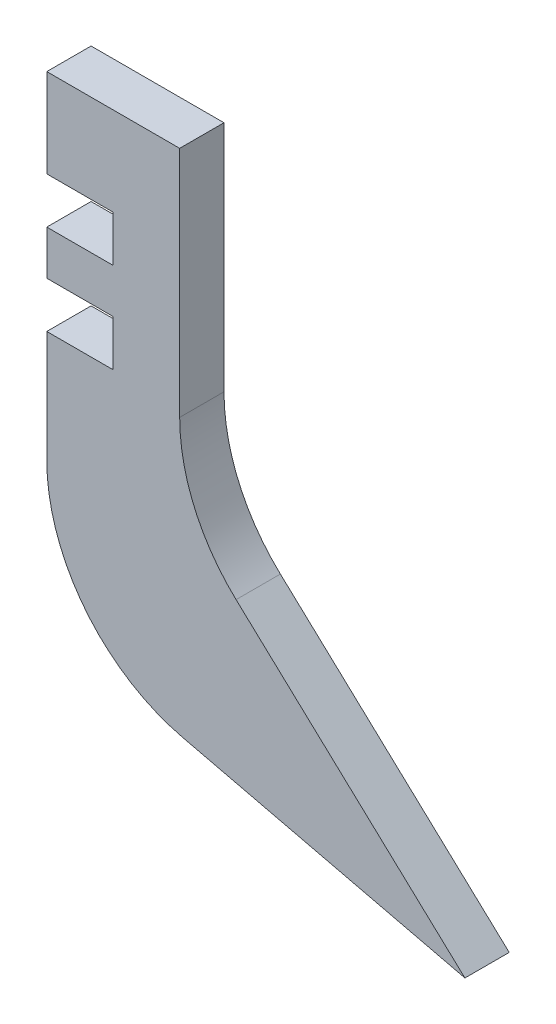
from build123d import *

# Parameters (mm, degrees)
BOSS_EXTRUDE1_DEPTH = 5
FILLET1_R           = 20
FILLET2_R           = 20
SKETCH3_W           = 7.5
SKETCH3_H           = 5.2
CUT_EXTRUDE2_DEPTH  = 5


with BuildPart() as part:
    # Sketch1 → Boss-Extrude1 (new body)
    with BuildSketch(Plane.XY):
        Polygon((0, 53.763883017), (0, 0), (47.193256778, -11.236116983), (15, 18.763883017), (15, 53.763883017), align=None)
    extrude(amount=BOSS_EXTRUDE1_DEPTH)

    # Fillet1
    fillet1_edges = [part.edges().sort_by_distance(p)[0] for p in [
        (0, 0, 2.5),
    ]]
    fillet(fillet1_edges, radius=FILLET1_R)

    # Fillet2
    fillet2_edges = [part.edges().sort_by_distance(p)[0] for p in [
        (15, 18.763883017, 2.5),
    ]]
    fillet(fillet2_edges, radius=FILLET2_R)

    # Sketch3 → Cut-Extrude2 (cut)
    with BuildSketch(Plane.XY):
        with Locations((3.75, 41.163883017)):
            Rectangle(SKETCH3_W, SKETCH3_H)
        with Locations((3.75, 30.963883017)):
            Rectangle(SKETCH3_W, SKETCH3_H)
    extrude(amount=CUT_EXTRUDE2_DEPTH, mode=Mode.SUBTRACT)


solid = part.part
